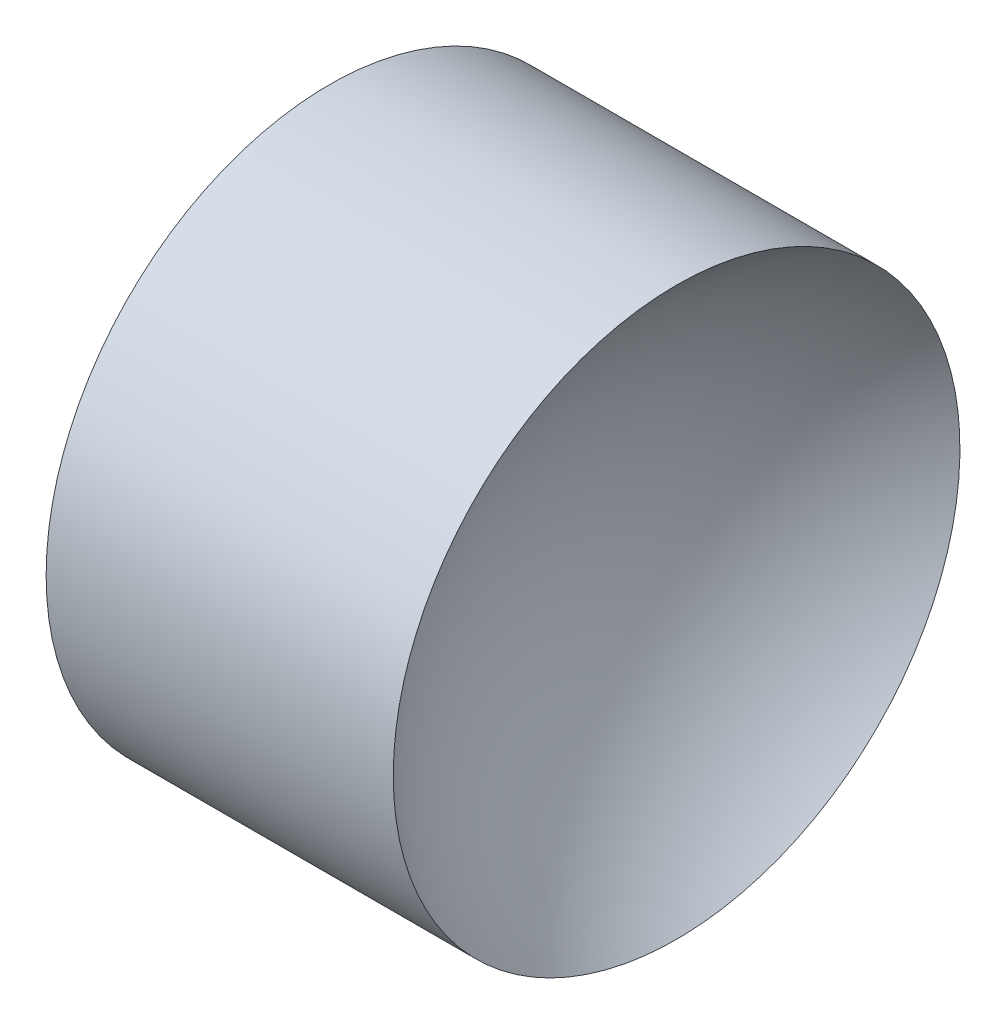
from build123d import *


with BuildPart() as part:
    # 草图1 → 旋转1 (revolve)
    with BuildSketch(Plane.XY):
        with BuildLine():
            Line((11.156989876, 6.515563046), (11.156989876, 8.515563046))
            Line((11.156989876, 8.515563046), (13.607143257, 8.515563046))
            ThreePointArc((13.607143257, 8.515563046), (12.906603183, 7.622675444), (12.656989876, 6.515563046))
            Line((12.656989876, 6.515563046), (11.156989876, 6.515563046))
        make_face()
    revolve(axis=Axis((10.342015318, 6.515563046, 0), (1, 0, 0)))


solid = part.part
